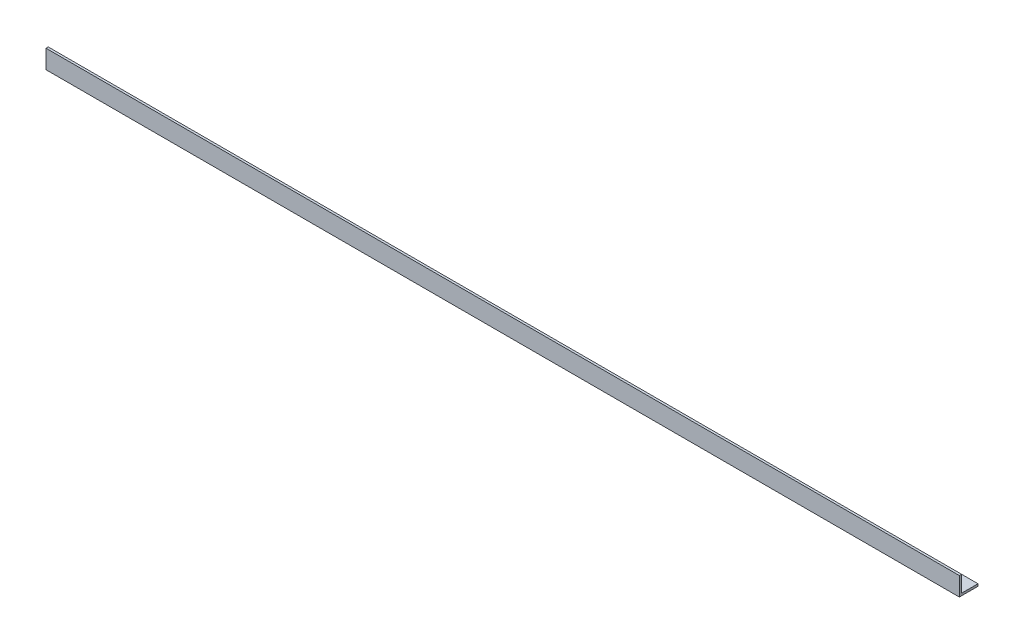
from build123d import *

# Parameters (mm, degrees)
EXTRUDE_2_DEPTH = 2450


with BuildPart() as part:
    # Эскиз1 → Вытянуть-Тонкостенный2 (new body)
    with BuildSketch(Plane(origin=(0, 0, 0), x_dir=(0, 0, -1), z_dir=(1, 0, 0))):
        Polygon((0, 50), (0, 0), (50, 0), (50, 6), (6, 6), (6, 50), align=None)
    extrude(amount=EXTRUDE_2_DEPTH)


solid = part.part
